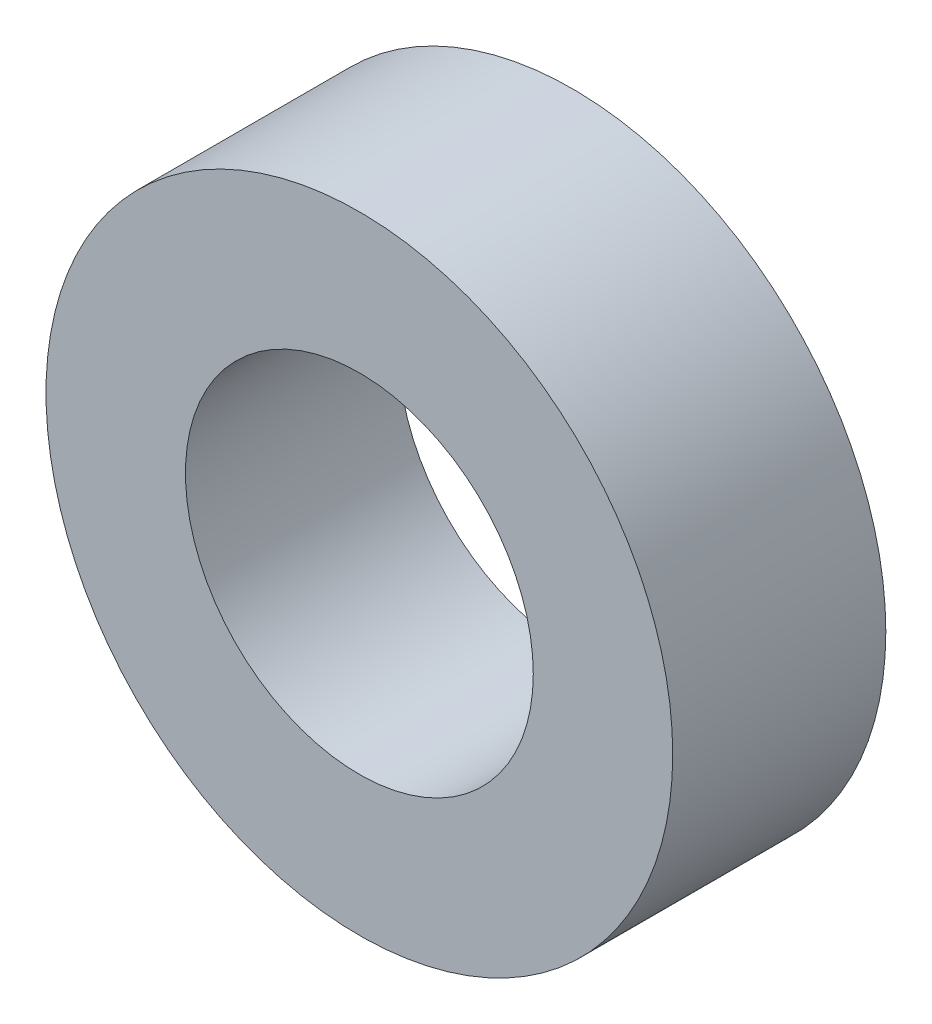
from build123d import *

# Parameters (mm, degrees)
SKETCH1_R           = 10
SKETCH1_R_2         = 5.55
BOSS_EXTRUDE1_DEPTH = 6.8


with BuildPart() as part:
    # Sketch1 → Boss-Extrude1 (new body)
    with BuildSketch(Plane.XY):
        Circle(SKETCH1_R)
        Circle(SKETCH1_R_2, mode=Mode.SUBTRACT)
    extrude(amount=BOSS_EXTRUDE1_DEPTH)


solid = part.part
